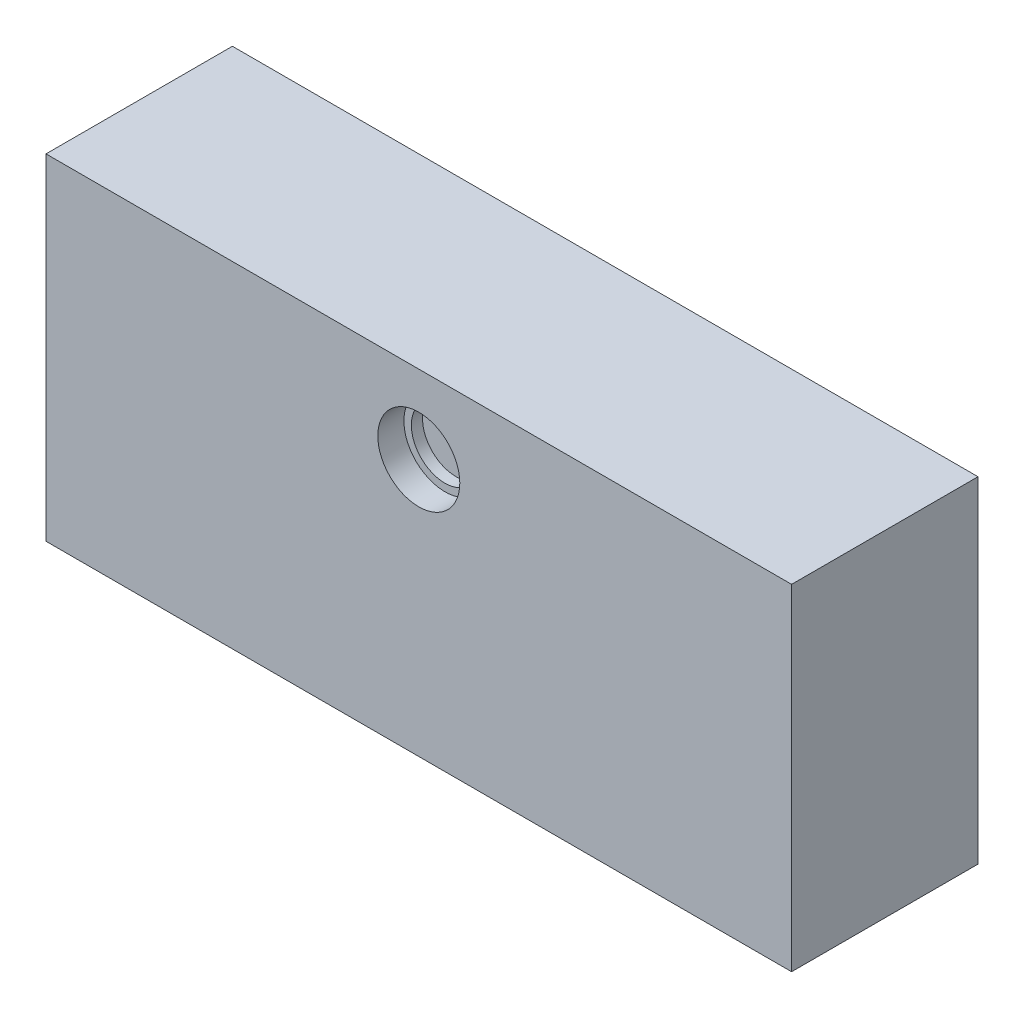
from build123d import *

# Parameters (mm, degrees)
SKETCH1_W           = 200
SKETCH1_H           = 90
BOSS_EXTRUDE1_DEPTH = 25
SKETCH2_R           = 9
CUT_EXTRUDE1_DEPTH  = 10
SKETCH2_4_R         = 11
SKETCH2_4_R_2       = 9
CUT_EXTRUDE2_DEPTH  = 7
SKETCH3_R           = 5
CUT_EXTRUDE3_DEPTH  = 15
SKETCH4_R           = 5
CUT_EXTRUDE4_DEPTH  = 15


with BuildPart() as part:
    # Sketch1 → Boss-Extrude1 (new, symmetric)
    with BuildSketch(Plane.XY):
        Rectangle(SKETCH1_W, SKETCH1_H)
    extrude(amount=BOSS_EXTRUDE1_DEPTH, both=True)

    # Sketch2 → Cut-Extrude1 (cut)
    with BuildSketch(Plane.XY.offset(25)):
        with Locations((0, 24)):
            Circle(SKETCH2_R)
    extrude(amount=-CUT_EXTRUDE1_DEPTH, mode=Mode.SUBTRACT)

    # Sketch2_4 → Cut-Extrude2 (cut)
    with BuildSketch(Plane.XY.offset(25)):
        with Locations((0, 24)):
            Circle(SKETCH2_4_R)
        with Locations((0, 24)):
            Circle(SKETCH2_4_R_2, mode=Mode.SUBTRACT)
    extrude(amount=-CUT_EXTRUDE2_DEPTH, mode=Mode.SUBTRACT)

    # Sketch3 → Cut-Extrude3 (cut)
    with BuildSketch(Plane.XZ.offset(45)):
        with Locations((-50, 0)):
            Circle(SKETCH3_R)
        with Locations((50, 0)):
            Circle(SKETCH3_R)
    extrude(amount=-CUT_EXTRUDE3_DEPTH, mode=Mode.SUBTRACT)

    # Sketch4 → Cut-Extrude4 (cut)
    with BuildSketch(Plane(origin=(0, 0, -25), x_dir=(-1, 0, 0), z_dir=(0, 0, -1))):
        with Locations((-50, -5)):
            Circle(SKETCH4_R)
        with Locations((50, -5)):
            Circle(SKETCH4_R)
    extrude(amount=-CUT_EXTRUDE4_DEPTH, mode=Mode.SUBTRACT)


solid = part.part
